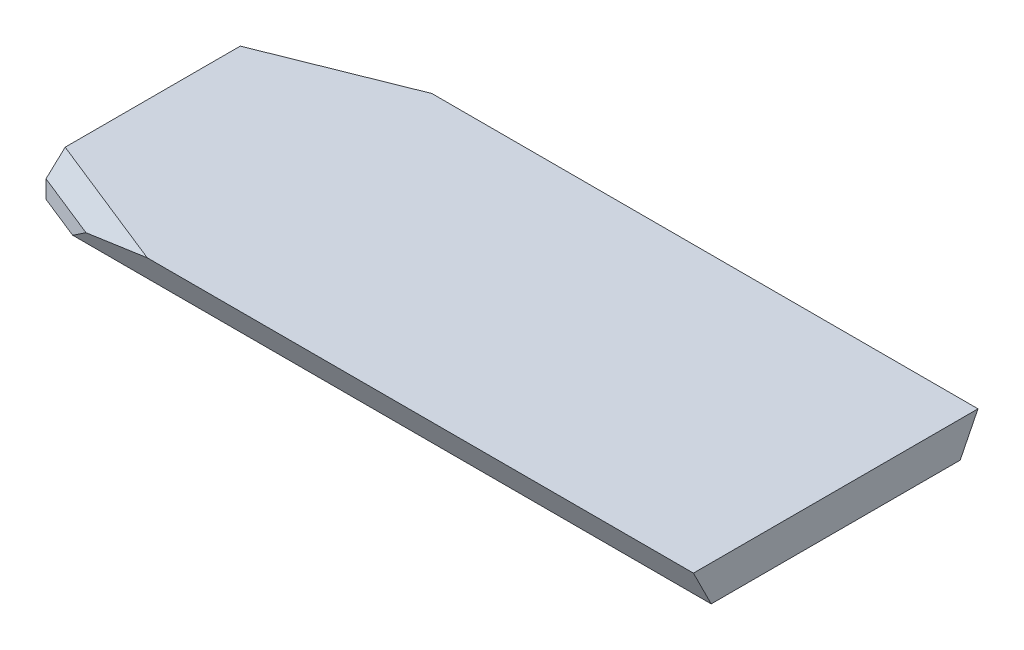
from build123d import *

# Parameters (mm, degrees)
BOSS_EXTRUDE2_DEPTH       = 96
CUT_EXTRUDE1_REACH        = 7
CHAMFER1_SIZE             = 2.5
F_4_0MM_DOWEL_HOLE1_D     = 4
F_4_0MM_DOWEL_HOLE1_DEPTH = 4
M4X0_7_TAPPED_HOLE1_D     = 3.3
M4X0_7_TAPPED_HOLE1_DEPTH = 4
M4X0_7_TAPPED_HOLE1_TIP   = 0.991420021


with BuildPart() as part:
    # Sketch3 → Boss-Extrude2 (new body)
    with BuildSketch(Plane(origin=(0, 0, 0), x_dir=(0, 0, -1), z_dir=(1, 0, 0))):
        Polygon((-20, 5), (-17.5, 0), (17.5, 0), (20, 5), align=None)
    extrude(amount=BOSS_EXTRUDE2_DEPTH)

    # Sketch5 → Cut-Extrude1 (cut, up to next)
    with BuildSketch(Plane(origin=(0, 5, 0), x_dir=(1, 0, 0), z_dir=(0, 1, 0)), mode=Mode.PRIVATE) as cut_extrude1_sk1:
        Polygon((0, 15), (12.5, 20), (0, 20), align=None)
    cut_extrude1_tool1 = extrude(cut_extrude1_sk1.sketch, amount=-CUT_EXTRUDE1_REACH, mode=Mode.PRIVATE) & part.part
    add(cut_extrude1_tool1.solids().sort_by_distance((4.166667, 5, -18.333333))[0], mode=Mode.SUBTRACT)
    # Sketch5 → Cut-Extrude1 (cut, up to next)
    with BuildSketch(Plane(origin=(0, 5, 0), x_dir=(1, 0, 0), z_dir=(0, 1, 0)), mode=Mode.PRIVATE) as cut_extrude1_sk2:
        Polygon((0, -20), (0, -15), (12.5, -20), align=None)
    cut_extrude1_tool2 = extrude(cut_extrude1_sk2.sketch, amount=-CUT_EXTRUDE1_REACH, mode=Mode.PRIVATE) & part.part
    add(cut_extrude1_tool2.solids().sort_by_distance((4.166667, 5, 18.333333))[0], mode=Mode.SUBTRACT)

    # Chamfer1
    chamfer1_edges = [part.edges().sort_by_distance(p)[0] for p in [
        (6.25, 5, -17.5),
        (6.25, 5, 17.5),
    ]]
    chamfer(chamfer1_edges, length=CHAMFER1_SIZE)

    # Ø4.0mm Dowel Hole1
    with Locations(Plane(origin=(0, 0, 0), x_dir=(-1, 0, 0), z_dir=(0, -1, 0))):
        with Locations((-23, 9), (-80, -9)):
            Hole(F_4_0MM_DOWEL_HOLE1_D / 2, depth=F_4_0MM_DOWEL_HOLE1_DEPTH)

    # M4x0.7 Tapped Hole1
    with Locations(Plane(origin=(0, 0, 0), x_dir=(-1, 0, 0), z_dir=(0, -1, 0))):
        with Locations((-23, -9), (-80, 9)):
            Hole(M4X0_7_TAPPED_HOLE1_D / 2, depth=M4X0_7_TAPPED_HOLE1_DEPTH)
            with Locations((0, 0, -(M4X0_7_TAPPED_HOLE1_DEPTH + M4X0_7_TAPPED_HOLE1_TIP / 2))):  # 118° drill point
                Cone(0, M4X0_7_TAPPED_HOLE1_D / 2, M4X0_7_TAPPED_HOLE1_TIP, mode=Mode.SUBTRACT)


solid = part.part
